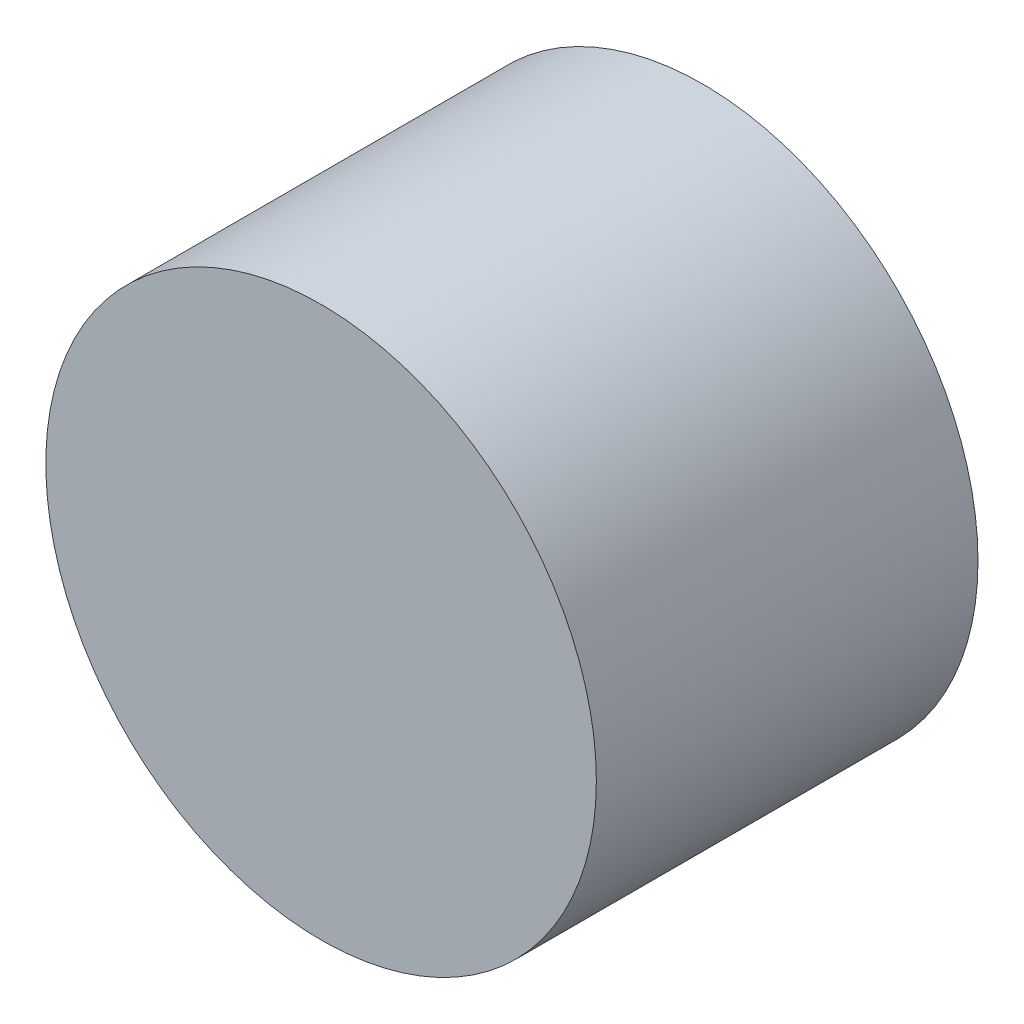
from build123d import *

# Parameters (mm, degrees)
ESQUISSE1_R               = 75.732278769
BOSS_EXTRU_1_DEPTH        = 100
BOSS_EXTRU_1_DEPTH_BACK   = 5
TROU_TARAUD_M8X1_01_D     = 7
TROU_TARAUD_M8X1_01_DEPTH = 50
TROU_TARAUD_M8X1_01_TIP   = 2.103012167


with BuildPart() as part:
    # Esquisse1 → Boss.-Extru.1 (new body, two sides)
    with BuildSketch(Plane.XY) as boss_extru_1_sk:
        Circle(ESQUISSE1_R)
    extrude(amount=BOSS_EXTRU_1_DEPTH)
    extrude(boss_extru_1_sk.sketch, amount=-BOSS_EXTRU_1_DEPTH_BACK)

    # Trou taraudé M8x1.01
    with Locations(Plane(origin=(0, 0, -5), x_dir=(-1, 0, 0), z_dir=(0, 0, -1))):
        with Locations((0, 0)):
            Hole(TROU_TARAUD_M8X1_01_D / 2, depth=TROU_TARAUD_M8X1_01_DEPTH)
            with Locations((0, 0, -(TROU_TARAUD_M8X1_01_DEPTH + TROU_TARAUD_M8X1_01_TIP / 2))):  # 118° drill point
                Cone(0, TROU_TARAUD_M8X1_01_D / 2, TROU_TARAUD_M8X1_01_TIP, mode=Mode.SUBTRACT)


solid = part.part
